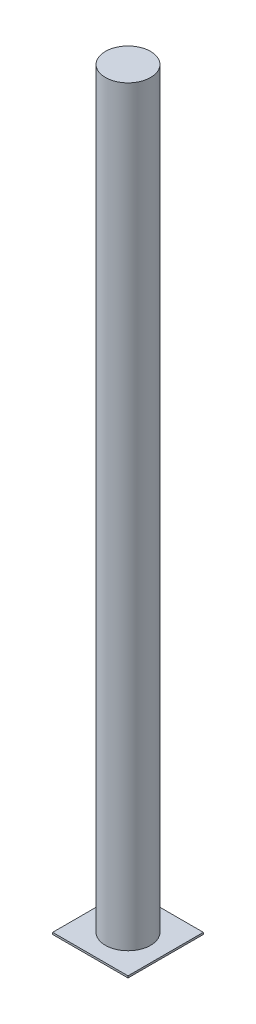
from build123d import *

# Parameters (mm, degrees)
SKETCH_1_R      = 60
EXTRUDE_1_DEPTH = 2000
SKETCH_2_W      = 200
SKETCH_2_H      = 200
EXTRUDE_2_DEPTH = 5


with BuildPart() as part:
    # 草圖1 → 填料-伸長1 (new body)
    with BuildSketch(Plane(origin=(0, 0, 0), x_dir=(1, 0, 0), z_dir=(0, 1, 0))):
        Circle(SKETCH_1_R)
    extrude(amount=EXTRUDE_1_DEPTH)

    # 草圖2 → 填料-伸長2 (add)
    with BuildSketch(Plane.XZ):
        Rectangle(SKETCH_2_W, SKETCH_2_H)
    extrude(amount=-EXTRUDE_2_DEPTH)


solid = part.part
